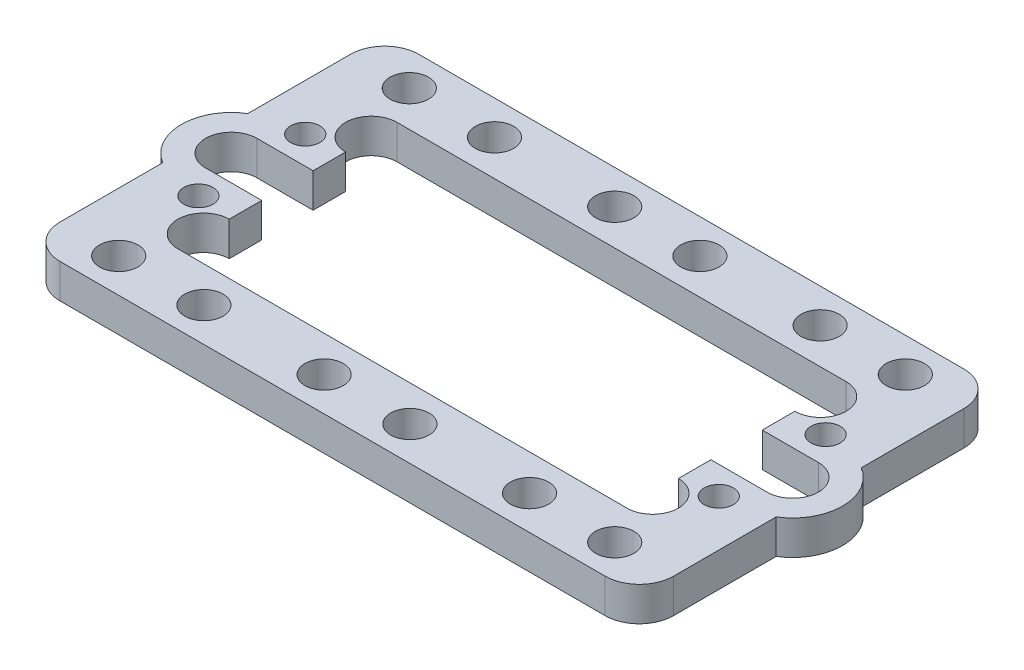
from build123d import *

# Parameters (mm, degrees)
MASS_DEPTH               = 3.175
SKETCH2_W                = 41.656
SKETCH2_H                = 4.7625
SERVO_HOLE_DEPTH         = 4.175
F_6_32_SERVO_MOUNT_D     = 2.7051
F_6_32_SERVO_MOUNT_DEPTH = 152.4
F_6_32_SERVO_MOUNT_TIP   = 0.81269403
CORNERS_R                = 3.175
SKETCH5_R                = 1.778
MOUNTING_HOLES_DEPTH     = 4.175


with BuildPart() as part:
    # Sketch1 → Mass (new body)
    with BuildSketch(Plane(origin=(0, 0, 0), x_dir=(1, 0, 0), z_dir=(0, 1, 0))):
        with BuildLine():
            Line((-28.448, 16.637), (28.448, 16.637))
            Line((28.448, 16.637), (28.448, 3.943058564))
            ThreePointArc((28.448, 3.943058564), (30.6578, 0), (28.448, -3.943058564))
            Line((28.448, -3.943058564), (28.448, -16.637))
            Line((28.448, -16.637), (-28.448, -16.637))
            Line((-28.448, -16.637), (-28.448, -3.943058564))
            ThreePointArc((-28.448, -3.943058564), (-30.6578, 0), (-28.448, 3.943058564))
            Line((-28.448, 3.943058564), (-28.448, 16.637))
        make_face()
    extrude(amount=MASS_DEPTH)

    # Sketch2 → Servo Hole (cut, through all)
    with BuildSketch(Plane(origin=(0, 3.175, 0), x_dir=(1, 0, 0), z_dir=(0, 1, 0))):
        with BuildLine():
            ThreePointArc((-20.828, -5.3975), (-23.20925, -7.77875), (-20.828, -10.16))
            Line((-20.828, -10.16), (20.828, -10.16))
            ThreePointArc((20.828, -10.16), (23.20925, -7.77875), (20.828, -5.3975))
            Line((20.828, -5.3975), (20.828, -2.38125))
            Line((20.828, -2.38125), (-20.828, -2.38125))
            Line((-20.828, -2.38125), (-20.828, -5.3975))
        make_face()
        Rectangle(SKETCH2_W, SKETCH2_H)
        with BuildLine():
            Line((-20.828, 5.3975), (-20.828, 2.38125))
            Line((-20.828, 2.38125), (20.828, 2.38125))
            Line((20.828, 2.38125), (20.828, 5.3975))
            ThreePointArc((20.828, 5.3975), (23.20925, 7.77875), (20.828, 10.16))
            Line((20.828, 10.16), (-20.828, 10.16))
            ThreePointArc((-20.828, 10.16), (-23.20925, 7.77875), (-20.828, 5.3975))
        make_face()
        with BuildLine():
            Line((20.828, 2.38125), (20.828, -2.38125))
            Line((20.828, -2.38125), (26.035, -2.38125))
            ThreePointArc((26.035, -2.38125), (28.41625, 0), (26.035, 2.38125))
            Line((26.035, 2.38125), (20.828, 2.38125))
        make_face()
        with BuildLine():
            Line((-26.035, -2.38125), (-20.828, -2.38125))
            Line((-20.828, -2.38125), (-20.828, 2.38125))
            Line((-20.828, 2.38125), (-26.035, 2.38125))
            ThreePointArc((-26.035, 2.38125), (-28.41625, 0), (-26.035, -2.38125))
        make_face()
    extrude(amount=-SERVO_HOLE_DEPTH, mode=Mode.SUBTRACT)

    # #6-32 Servo Mount
    with Locations(Plane(origin=(0, 3.175, 0), x_dir=(1, 0, 0), z_dir=(0, 1, 0))):
        with Locations((24.13, 4.953), (24.13, -4.953), (-24.13, -4.953), (-24.13, 4.953)):
            Hole(F_6_32_SERVO_MOUNT_D / 2, depth=F_6_32_SERVO_MOUNT_DEPTH)
            with Locations((0, 0, -(F_6_32_SERVO_MOUNT_DEPTH + F_6_32_SERVO_MOUNT_TIP / 2))):  # 118° drill point
                Cone(0, F_6_32_SERVO_MOUNT_D / 2, F_6_32_SERVO_MOUNT_TIP, mode=Mode.SUBTRACT)

    # Corners
    corners_edges = [part.edges().sort_by_distance(p)[0] for p in [
        (-28.448, 1.5875, -16.637),
        (28.448, 1.5875, -16.637),
        (28.448, 1.5875, 16.637),
        (-28.448, 1.5875, 16.637),
    ]]
    fillet(corners_edges, radius=CORNERS_R)

    # Sketch5 → Mounting Holes (cut, through all)
    with BuildSketch(Plane(origin=(0, 3.175, 0), x_dir=(1, 0, 0), z_dir=(0, 1, 0))):
        with Locations((-22.9997, 13.4747)):
            Circle(SKETCH5_R)
        with Locations((22.9997, 13.4747)):
            Circle(SKETCH5_R)
        with Locations((22.9997, -13.4747)):
            Circle(SKETCH5_R)
        with Locations((-22.9997, -13.4747)):
            Circle(SKETCH5_R)
        with Locations((-15.1003, 13.4747)):
            Circle(SKETCH5_R)
        with Locations((-3.9497, 13.4747)):
            Circle(SKETCH5_R)
        with Locations((3.9497, 13.4747)):
            Circle(SKETCH5_R)
        with Locations((15.1003, 13.4747)):
            Circle(SKETCH5_R)
        with Locations((15.1003, -13.4747)):
            Circle(SKETCH5_R)
        with Locations((4.0005, -13.4747)):
            Circle(SKETCH5_R)
        with Locations((-3.9497, -13.4747)):
            Circle(SKETCH5_R)
        with Locations((-15.1003, -13.4747)):
            Circle(SKETCH5_R)
    extrude(amount=-MOUNTING_HOLES_DEPTH, mode=Mode.SUBTRACT)


solid = part.part
